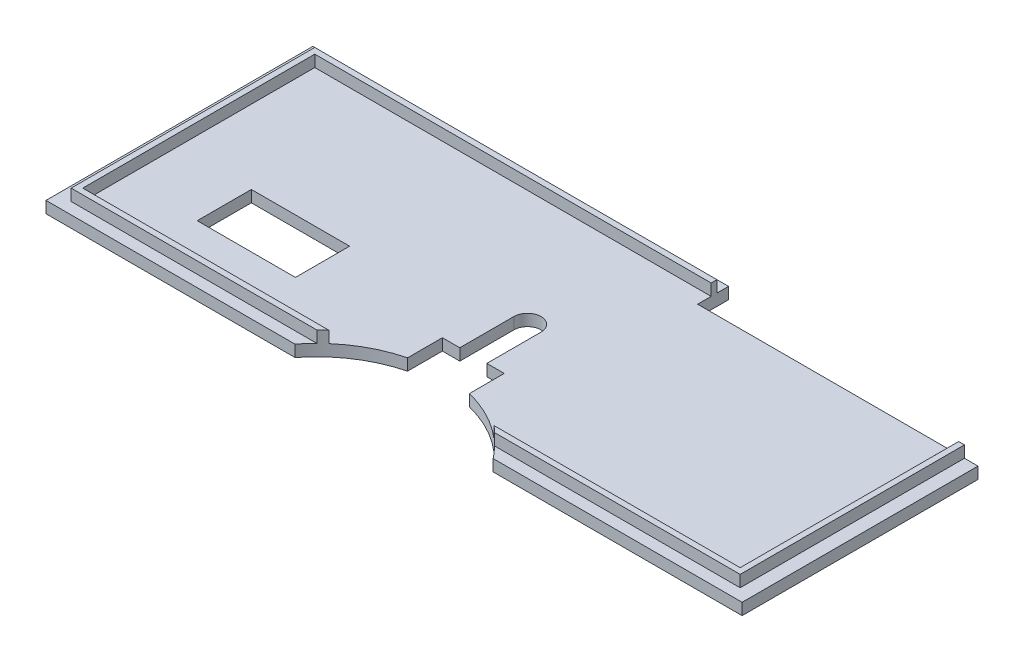
from build123d import *

# Parameters (mm, degrees)
SKETCH2_W           = 180
SKETCH2_H           = 69
BOSS_EXTRUDE1_DEPTH = 3
SKETCH3_W           = 173
SKETCH3_H           = 63
SKETCH3_W_2         = 170
SKETCH3_H_2         = 60
BOSS_EXTRUDE2_DEPTH = 3
SKETCH4_W           = 25.4
SKETCH4_H           = 14
CUT_EXTRUDE1_DEPTH  = 10
SKETCH5_W           = 69
SKETCH5_H           = 1.5
CUT_EXTRUDE2_DEPTH  = 3
SKETCH6_W           = 1.5
SKETCH6_H           = 3.5
CUT_EXTRUDE3_DEPTH  = 3
SKETCH7_R           = 3.5
CUT_EXTRUDE4_DEPTH  = 3
SKETCH8_R           = 32.5
CUT_EXTRUDE5_DEPTH  = 10
SKETCH9_W           = 16
SKETCH9_H           = 16
CUT_EXTRUDE6_DEPTH  = 10
SKETCH10_W          = 72.5
SKETCH10_H          = 8
CUT_EXTRUDE7_DEPTH  = 10
SKETCH11_W          = 7
SKETCH11_H          = 14
CUT_EXTRUDE8_DEPTH  = 10


with BuildPart() as part:
    # Sketch2 → Boss-Extrude1 (new body)
    with BuildSketch(Plane(origin=(0, 0, 0), x_dir=(1, 0, 0), z_dir=(0, 1, 0))):
        Rectangle(SKETCH2_W, SKETCH2_H)
    extrude(amount=BOSS_EXTRUDE1_DEPTH)

    # Sketch3 → Boss-Extrude2 (add)
    with BuildSketch(Plane(origin=(0, 3, 0), x_dir=(1, 0, 0), z_dir=(0, 1, 0))):
        Rectangle(SKETCH3_W, SKETCH3_H)
        Rectangle(SKETCH3_W_2, SKETCH3_H_2, mode=Mode.SUBTRACT)
    extrude(amount=BOSS_EXTRUDE2_DEPTH)

    # Sketch4 → Cut-Extrude1 (cut)
    with BuildSketch(Plane.XZ):
        with Locations((-53.2, 12.5)):
            Rectangle(SKETCH4_W, SKETCH4_H)
    extrude(amount=-CUT_EXTRUDE1_DEPTH, mode=Mode.SUBTRACT)

    # Sketch5 → Cut-Extrude2 (cut)
    with BuildSketch(Plane(origin=(0, 6, 0), x_dir=(1, 0, 0), z_dir=(0, 1, 0))):
        with Locations((52, 30.75)):
            Rectangle(SKETCH5_W, SKETCH5_H)
    extrude(amount=-CUT_EXTRUDE2_DEPTH, mode=Mode.SUBTRACT)

    # Sketch6 → Cut-Extrude3 (cut)
    with BuildSketch(Plane(origin=(0, 6, 0), x_dir=(1, 0, 0), z_dir=(0, 1, 0))):
        with Locations((85.75, 28.25)):
            Rectangle(SKETCH6_W, SKETCH6_H)
    extrude(amount=-CUT_EXTRUDE3_DEPTH, mode=Mode.SUBTRACT)

    # Sketch7 → Cut-Extrude4 (cut)
    with BuildSketch(Plane.XZ):
        Circle(SKETCH7_R)
    extrude(amount=-CUT_EXTRUDE4_DEPTH, mode=Mode.SUBTRACT)

    # Sketch8 → Cut-Extrude5 (cut)
    with BuildSketch(Plane.XZ):
        with Locations((0, 54.5)):
            Circle(SKETCH8_R)
    extrude(amount=-CUT_EXTRUDE5_DEPTH, mode=Mode.SUBTRACT)

    # Sketch9 → Cut-Extrude6 (cut)
    with BuildSketch(Plane.XZ):
        with Locations((0, 22)):
            Rectangle(SKETCH9_W, SKETCH9_H)
    extrude(amount=-CUT_EXTRUDE6_DEPTH, mode=Mode.SUBTRACT)

    # Sketch10 → Cut-Extrude7 (cut)
    with BuildSketch(Plane(origin=(0, 3, 0), x_dir=(1, 0, 0), z_dir=(0, 1, 0))):
        with Locations((53.75, 30.5)):
            Rectangle(SKETCH10_W, SKETCH10_H)
    extrude(amount=-CUT_EXTRUDE7_DEPTH, mode=Mode.SUBTRACT)

    # Sketch11 → Cut-Extrude8 (cut)
    with BuildSketch(Plane(origin=(0, 0, 0), x_dir=(-1, 0, 0), z_dir=(0, -1, 0))):
        with Locations((0, -7)):
            Rectangle(SKETCH11_W, SKETCH11_H)
    extrude(amount=-CUT_EXTRUDE8_DEPTH, mode=Mode.SUBTRACT)


solid = part.part
